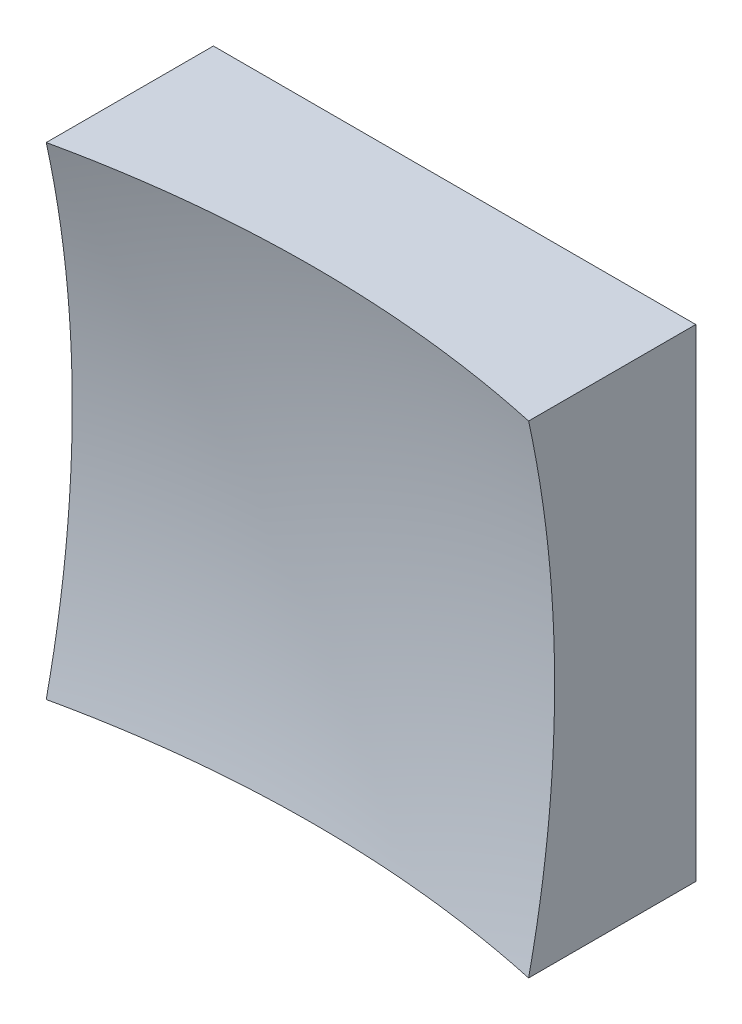
from build123d import *

# Parameters (mm, degrees)
SKETCH_1_W      = 12.5
SKETCH_1_H      = 12.5
EXTRUDE_1_DEPTH = 10


with BuildPart() as part:
    # 草图1 → 凸台-拉伸1 (new body)
    with BuildSketch(Plane.XY):
        Rectangle(SKETCH_1_W, SKETCH_1_H)
    extrude(amount=EXTRUDE_1_DEPTH)

    # 草图2 → 切除-旋转2 (revolve, cut)
    with BuildSketch(Plane(origin=(0, 0, 0), x_dir=(1, 0, 0), z_dir=(0, 1, 0))):
        with BuildLine():
            Line((29.245363854, -26.313544061), (0, -26.313544061))
            Line((0, -26.313544061), (0, -3))
            ThreePointArc((0, -3), (18.700351893, -9.541593424), (29.245363854, -26.313544061))
        make_face()
    revolve(axis=Axis((0, 0, 26.313544061), (0, 0, -1)), mode=Mode.SUBTRACT)


solid = part.part
